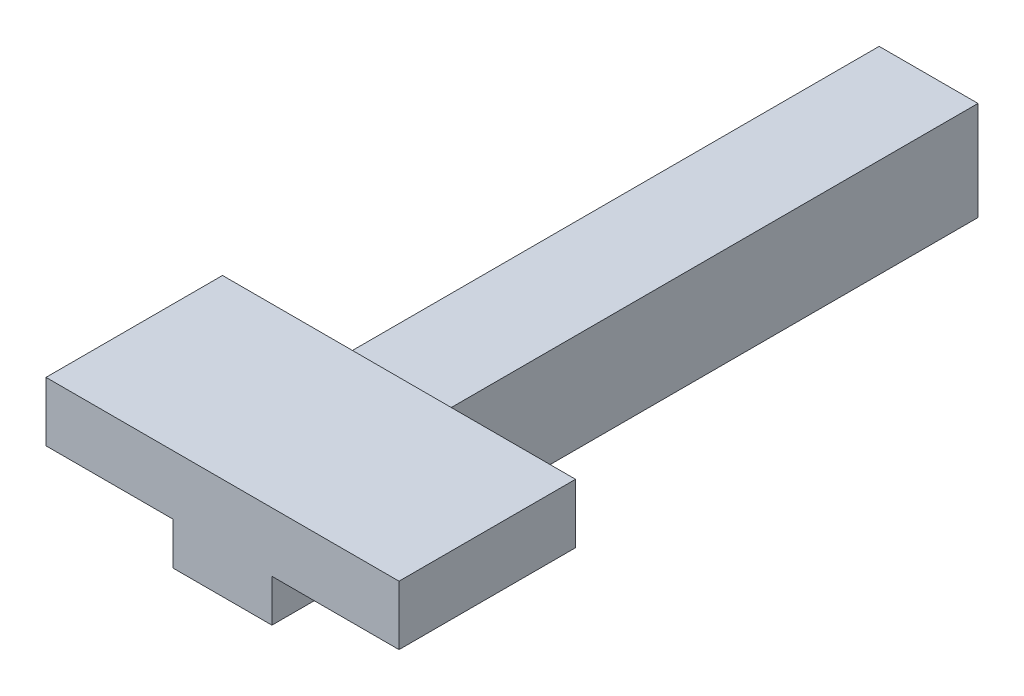
from build123d import *

# Parameters (mm, degrees)
SKETCH1_W                = 70
SKETCH1_H                = 70
BOSS_EXTRUDE1_DEPTH      = 500
SKETCH2_W                = 250
SKETCH2_H                = 125
BOSS_EXTRUDE2_DEPTH      = 2
BOSS_EXTRUDE2_DEPTH_BACK = 40


with BuildPart() as part:
    # Sketch1 → Boss-Extrude1 (new body)
    with BuildSketch(Plane.XY):
        Rectangle(SKETCH1_W, SKETCH1_H)
    extrude(amount=BOSS_EXTRUDE1_DEPTH)

    # Sketch2 → Boss-Extrude2 (add, two sides)
    with BuildSketch(Plane(origin=(0, 35, 0), x_dir=(1, 0, 0), z_dir=(0, 1, 0))) as boss_extrude2_sk:
        with Locations((0, -437.5)):
            Rectangle(SKETCH2_W, SKETCH2_H)
    extrude(amount=BOSS_EXTRUDE2_DEPTH)
    extrude(boss_extrude2_sk.sketch, amount=-BOSS_EXTRUDE2_DEPTH_BACK)


solid = part.part
